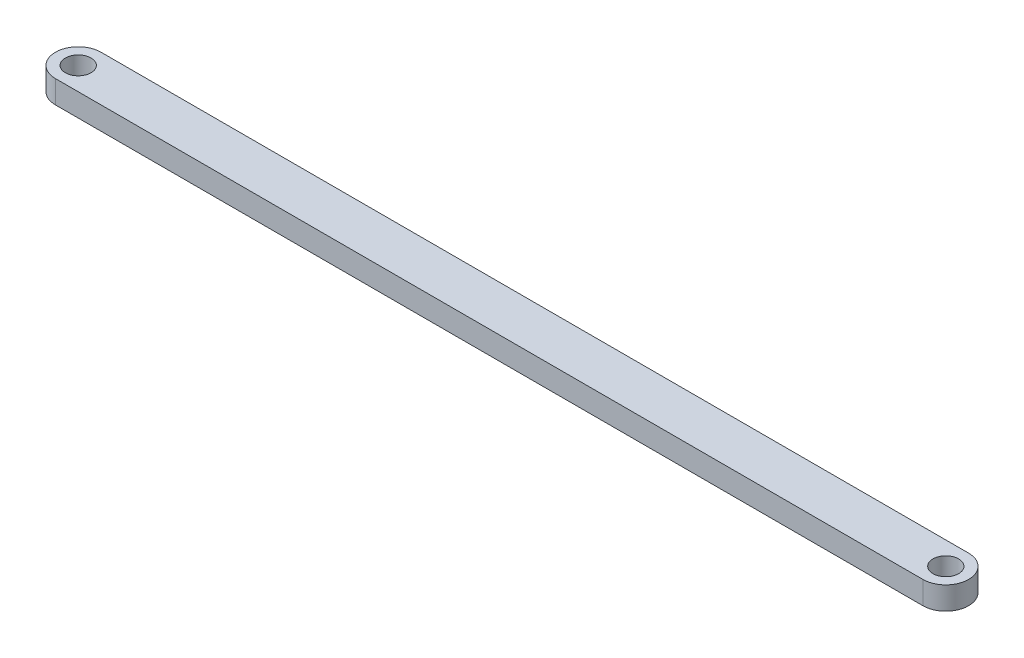
from build123d import *

# Parameters (mm, degrees)
BOSS_EXTRUDE1_DEPTH             = 3.175
F_9_64_0_14063_DIAMETER_HOLE1_D = 3.572002


with BuildPart() as part:
    # Sketch1 → Boss-Extrude1 (new body)
    with BuildSketch(Plane(origin=(0, 0, 0), x_dir=(1, 0, 0), z_dir=(0, 1, 0))):
        with BuildLine():
            Line((60.366783, -3.175), (-60.366783, -3.175))
            ThreePointArc((-60.366783, -3.175), (-63.541783, 0), (-60.366783, 3.175))
            Line((-60.366783, 3.175), (60.366783, 3.175))
            ThreePointArc((60.366783, 3.175), (63.541783, 0), (60.366783, -3.175))
        make_face()
    extrude(amount=BOSS_EXTRUDE1_DEPTH)

    # 9/64 (0.14063) Diameter Hole1 (through all)
    with Locations(Plane(origin=(0, 3.175, 0), x_dir=(1, 0, 0), z_dir=(0, 1, 0))):
        with Locations((60.366783, 0), (-60.366783, 0)):
            Hole(F_9_64_0_14063_DIAMETER_HOLE1_D / 2)


solid = part.part
